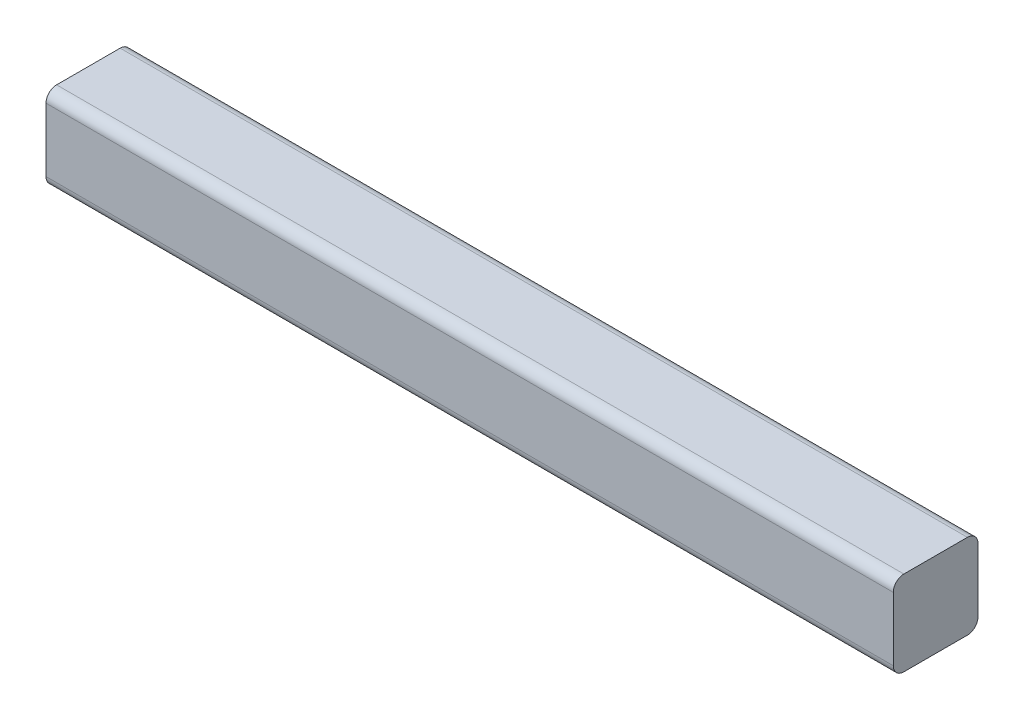
from build123d import *

# Parameters (mm, degrees)
SKETCH1_W           = 12.7
SKETCH1_H           = 12.7
BOSS_EXTRUDE1_DEPTH = 127
FILLET1_R           = 1.5875


with BuildPart() as part:
    # Sketch1 → Boss-Extrude1 (new body)
    with BuildSketch(Plane(origin=(0, 0, 0), x_dir=(0, 0, -1), z_dir=(1, 0, 0))):
        with Locations((-6.35, -6.35)):
            Rectangle(SKETCH1_W, SKETCH1_H)
    extrude(amount=BOSS_EXTRUDE1_DEPTH)

    # Fillet1
    fillet1_edges = [part.edges().sort_by_distance(p)[0] for p in [
        (63.5, -12.7, 0),
        (63.5, -12.7, 12.7),
        (63.5, 0, 12.7),
        (63.5, 0, 0),
    ]]
    fillet(fillet1_edges, radius=FILLET1_R)


solid = part.part
